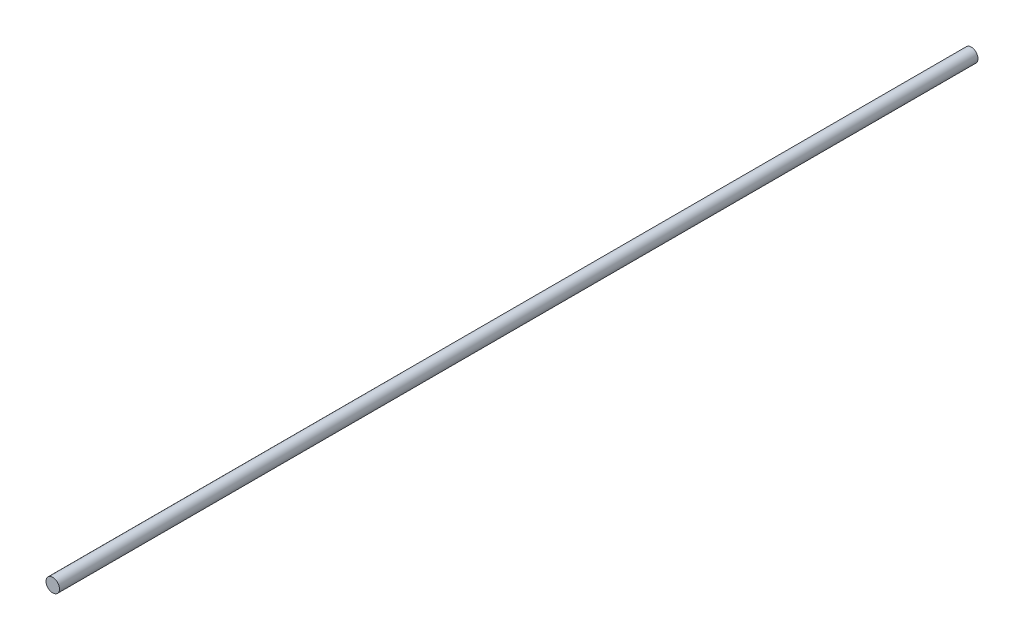
from build123d import *

# Parameters (mm, degrees)
SKETCH_1_R      = 1.5875
EXTRUDE_1_DEPTH = 215.9


with BuildPart() as part:
    # 스케치1 → 보스-돌출1 (new body)
    with BuildSketch(Plane.XY):
        Circle(SKETCH_1_R)
    extrude(amount=EXTRUDE_1_DEPTH)


solid = part.part
